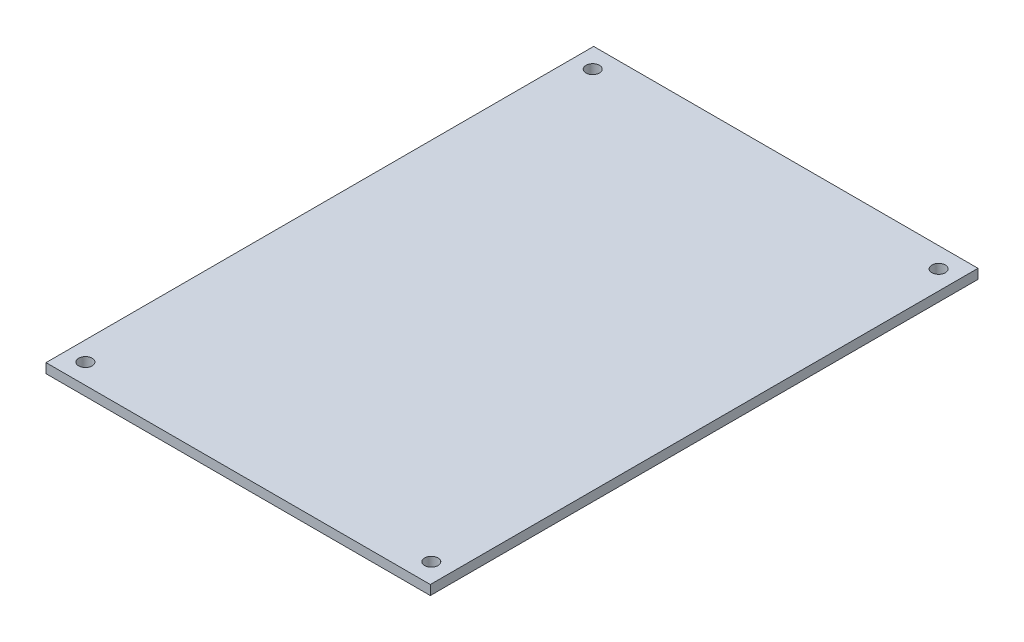
from build123d import *

# Parameters (mm, degrees)
SKETCH1_W           = 101.6
SKETCH1_H           = 144.78
BOSS_EXTRUDE1_DEPTH = 2.54
SKETCH2_R           = 1.778
CUT_EXTRUDE1_DEPTH  = 2.54


with BuildPart() as part:
    # Sketch1 → Boss-Extrude1 (new body)
    with BuildSketch(Plane(origin=(0, 0, 0), x_dir=(1, 0, 0), z_dir=(0, 1, 0))):
        Rectangle(SKETCH1_W, SKETCH1_H)
    extrude(amount=BOSS_EXTRUDE1_DEPTH)

    # Sketch2 → Cut-Extrude1 (cut)
    with BuildSketch(Plane(origin=(0, 2.54, 0), x_dir=(1, 0, 0), z_dir=(0, 1, 0))):
        with Locations((-45.72, 67.056)):
            Circle(SKETCH2_R)
        with Locations((-45.72, -67.056)):
            Circle(SKETCH2_R)
        with Locations((45.72, -67.056)):
            Circle(SKETCH2_R)
        with Locations((45.72, 67.056)):
            Circle(SKETCH2_R)
    extrude(amount=-CUT_EXTRUDE1_DEPTH, mode=Mode.SUBTRACT)


solid = part.part
